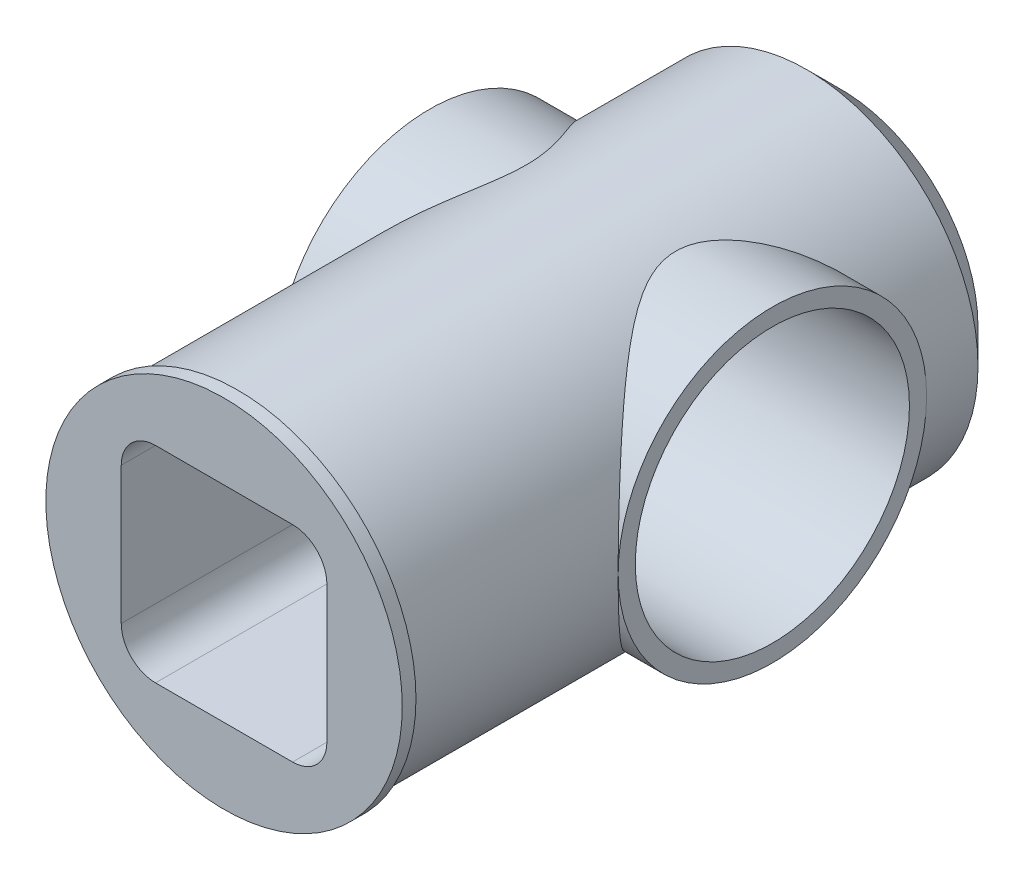
from build123d import *

# Parameters (mm, degrees)
SKETCH1_R               = 25
BOSS_EXTRUDE3_DEPTH     = 100
SKETCH4_R               = 22.5
BOSS_EXTRUDE4_DEPTH     = 25
SKETCH5_R               = 20
CUT_EXTRUDE2_DEPTH      = 50
CHAMFER1_SIZE           = 5
SKETCH9_W               = 10
SKETCH9_H               = 60.112874217
CUT_EXTRUDE3_DEPTH      = 26.0000001
CUT_EXTRUDE3_DEPTH_BACK = 26.0000001
CUT_EXTRUDE4_DEPTH      = 30
SKETCH12_R              = 26
SKETCH12_R_2            = 25
BOSS_EXTRUDE6_DEPTH     = 2


with BuildPart() as part:
    # Sketch1 → Boss-Extrude3 (new body)
    with BuildSketch(Plane.XY):
        Circle(SKETCH1_R)
    extrude(amount=BOSS_EXTRUDE3_DEPTH)

    # Sketch4 → Boss-Extrude4 (add, symmetric)
    with BuildSketch(Plane(origin=(0, 0, 0), x_dir=(0, 0, -1), z_dir=(1, 0, 0))):
        with Locations((-35, 0)):
            Circle(SKETCH4_R)
    extrude(amount=BOSS_EXTRUDE4_DEPTH, both=True)

    # Sketch5 → Cut-Extrude2 (cut)
    with BuildSketch(Plane(origin=(25, 0, 0), x_dir=(0, 0, -1), z_dir=(1, 0, 0))):
        with Locations((-35, 0)):
            Circle(SKETCH5_R)
    extrude(amount=-CUT_EXTRUDE2_DEPTH, mode=Mode.SUBTRACT)

    # Chamfer1
    chamfer1_edges = [part.edges().sort_by_distance(p)[0] for p in [
        (-25, 0, 0),
    ]]
    chamfer(chamfer1_edges, length=CHAMFER1_SIZE)

    # Sketch9 → Cut-Extrude3 (cut, two sides)
    with BuildSketch(Plane(origin=(0, 0, 0), x_dir=(0, 0, -1), z_dir=(1, 0, 0))) as cut_extrude3_sk:
        with Locations((-95, -5.056437109)):
            Rectangle(SKETCH9_W, SKETCH9_H)
    extrude(amount=CUT_EXTRUDE3_DEPTH, mode=Mode.SUBTRACT)
    extrude(cut_extrude3_sk.sketch, amount=-CUT_EXTRUDE3_DEPTH_BACK, mode=Mode.SUBTRACT)

    # Sketch11 → Cut-Extrude4 (cut)
    with BuildSketch(Plane.XY.offset(90)):
        with BuildLine():
            Line((-10, 15), (10, 15))
            ThreePointArc((10, 15), (13.535533906, 13.535533906), (15, 10))
            Line((15, 10), (15, -10))
            ThreePointArc((15, -10), (13.535533906, -13.535533906), (10, -15))
            Line((10, -15), (-10, -15))
            ThreePointArc((-10, -15), (-13.535533906, -13.535533906), (-15, -10))
            Line((-15, -10), (-15, 10))
            ThreePointArc((-15, 10), (-13.535533906, 13.535533906), (-10, 15))
        make_face()
    extrude(amount=-CUT_EXTRUDE4_DEPTH, mode=Mode.SUBTRACT)

    # Sketch12 → Boss-Extrude6 (add)
    with BuildSketch(Plane.XY.offset(90)):
        Circle(SKETCH12_R)
        Circle(SKETCH12_R_2, mode=Mode.SUBTRACT)
    extrude(amount=-BOSS_EXTRUDE6_DEPTH)


solid = part.part
